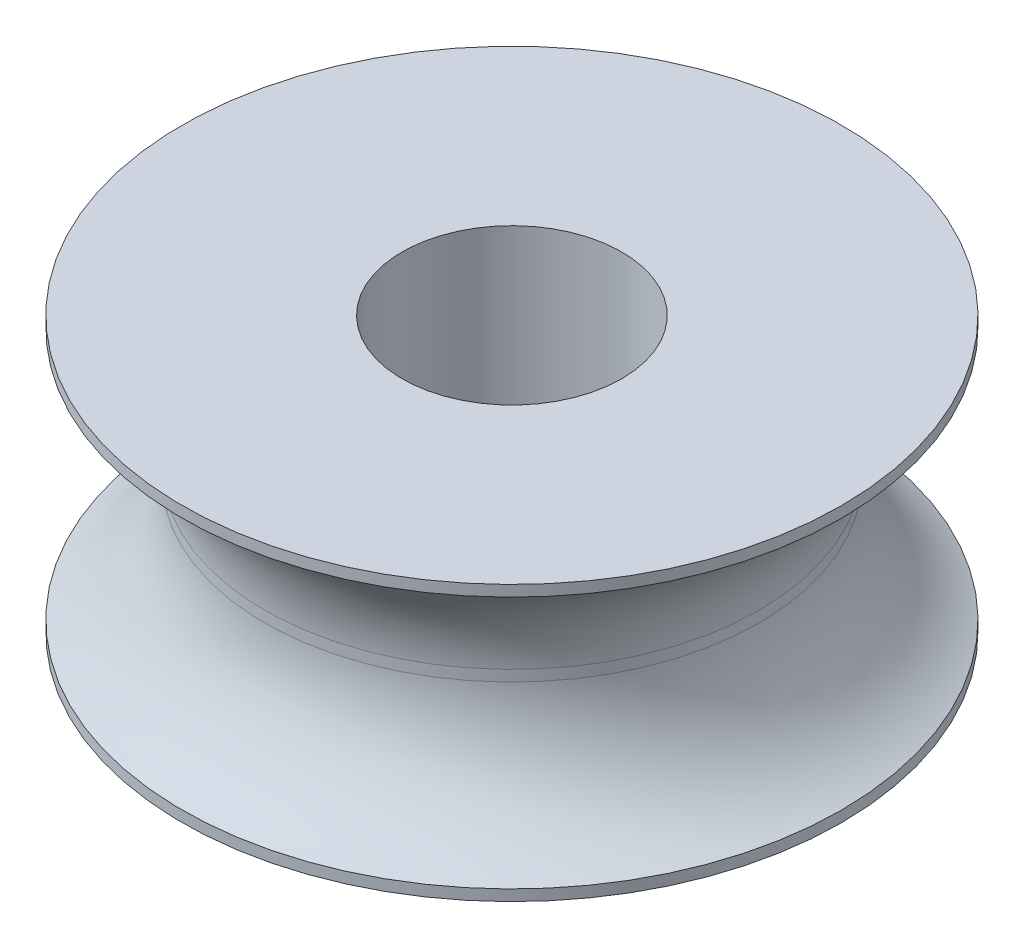
from build123d import *


with BuildPart() as part:
    # Sketch2 → Revolve1 (revolve)
    with BuildSketch(Plane.XY):
        with BuildLine():
            Line((2, 2.5), (2, -2.5))
            Line((2, -2.5), (6, -2.5))
            Line((6, -2.5), (6, -2.3))
            ThreePointArc((6, -2.3), (4.935246844, -1.414604424), (4.5, -0.1))
            Line((4.5, -0.1), (4.5, 0.1))
            ThreePointArc((4.5, 0.1), (4.935246844, 1.414604424), (6, 2.3))
            Line((6, 2.3), (6, 2.5))
            Line((6, 2.5), (2, 2.5))
        make_face()
    revolve(axis=Axis((0, -2.5, 0), (0, 1, 0)))


solid = part.part
